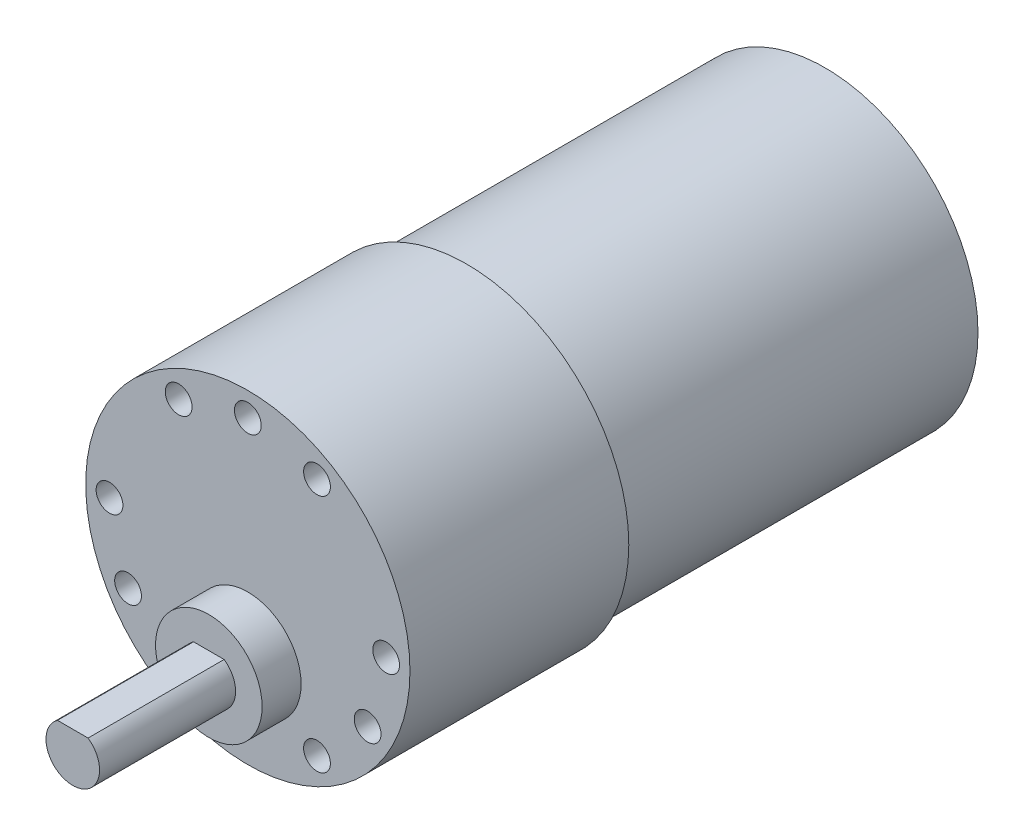
from build123d import *

# Parameters (mm, degrees)
SKETCH1_R           = 18.161
BOSS_EXTRUDE1_DEPTH = 24.511
SKETCH5_R           = 5.969
BOSS_EXTRUDE5_DEPTH = 4.3688
BOSS_EXTRUDE6_DEPTH = 15.24
CIRPATTERN2_COUNT   = 12
SKETCH2_R           = 17.145
BOSS_EXTRUDE2_DEPTH = 40.132
SKETCH3_R           = 3.048
BOSS_EXTRUDE3_DEPTH = 3.81
SKETCH13_R          = 16.637
CUT_EXTRUDE1_DEPTH  = 1.016
SKETCH15_W          = 2.54
SKETCH15_H          = 5.08
SKETCH15_R          = 0.4445
BOSS_EXTRUDE7_DEPTH = 0.254
SKETCH16_W          = 2.54
SKETCH16_H          = 5.08
SKETCH16_R          = 0.678606607
BOSS_EXTRUDE8_DEPTH = 0.254


with BuildPart() as part:
    # Sketch1 → Boss-Extrude1 (new body)
    with BuildSketch(Plane.XY):
        Circle(SKETCH1_R)
    extrude(amount=BOSS_EXTRUDE1_DEPTH)

    # Sketch5 → Boss-Extrude5 (add)
    with BuildSketch(Plane.XY.offset(24.511)):
        with Locations((0, -7.366)):
            Circle(SKETCH5_R)
    extrude(amount=BOSS_EXTRUDE5_DEPTH)

    # Sketch6 → Boss-Extrude6 (add)
    with BuildSketch(Plane.XY.offset(28.8798)):
        with BuildLine():
            Line((-1.715657017, -4.905), (1.715657017, -4.905))
            ThreePointArc((1.715657017, -4.905), (0, -10.366), (-1.715657017, -4.905))
        make_face()
    extrude(amount=BOSS_EXTRUDE6_DEPTH)

    # Sketch12 → Ø3.0mm Dowel Hole1 (revolve, cut)
    with BuildSketch(Plane(origin=(0, 15.494, 24.511), x_dir=(0, -1, 0), z_dir=(1, 0, 0))):
        Polygon((0, 0), (0, 11.061290929), (1.5, 10.16), (1.5, 0), align=None)
    f_3_0mm_dowel_hole1 = revolve(axis=Axis((0, 15.494, 30.861), (0, 0, -1)), mode=Mode.SUBTRACT)

    # CirPattern2: Ø3.0mm Dowel Hole1 ×12 about axis, 3 skipped
    cirpattern2_axis = Axis((0, 0, 0), (0, 0, -1))
    add([f_3_0mm_dowel_hole1.rotate(cirpattern2_axis, i * 360 / CIRPATTERN2_COUNT) for i in range(1, CIRPATTERN2_COUNT) if i not in (2, 6, 10)], mode=Mode.SUBTRACT)

    # Sketch2 → Boss-Extrude2 (add)
    with BuildSketch(Plane(origin=(0, 0, 0), x_dir=(-1, 0, 0), z_dir=(0, 0, -1))):
        Circle(SKETCH2_R)
    extrude(amount=BOSS_EXTRUDE2_DEPTH)

    # Sketch3 → Boss-Extrude3 (add)
    with BuildSketch(Plane(origin=(0, 0, -40.132), x_dir=(-1, 0, 0), z_dir=(0, 0, -1))):
        Circle(SKETCH3_R)
    extrude(amount=BOSS_EXTRUDE3_DEPTH)

    # Sketch13 → Cut-Extrude1 (cut)
    with BuildSketch(Plane(origin=(0, 0, -40.132), x_dir=(-1, 0, 0), z_dir=(0, 0, -1))):
        Circle(SKETCH13_R)
    extrude(amount=-CUT_EXTRUDE1_DEPTH, mode=Mode.SUBTRACT)

    # Sketch15 → Boss-Extrude7 (add, symmetric)
    with BuildSketch(Plane(origin=(0, 0, 0), x_dir=(0.64278761, -0.766044443, 0), z_dir=(0.766044443, 0.64278761, 0))):
        with Locations((10.16, 41.656)):
            Rectangle(SKETCH15_W, SKETCH15_H)
        with Locations((10.16, 42.926)):
            Circle(SKETCH15_R, mode=Mode.SUBTRACT)
    extrude(amount=BOSS_EXTRUDE7_DEPTH, both=True)

    # Sketch16 → Boss-Extrude8 (add, symmetric)
    with BuildSketch(Plane(origin=(0, 0, 0), x_dir=(-0.258819045, -0.965925826, 0), z_dir=(0.965925826, -0.258819045, 0))):
        with Locations((11.43, 41.656)):
            Rectangle(SKETCH16_W, SKETCH16_H)
        with Locations((11.43, 42.926)):
            Circle(SKETCH16_R, mode=Mode.SUBTRACT)
    extrude(amount=BOSS_EXTRUDE8_DEPTH, both=True)


solid = part.part
